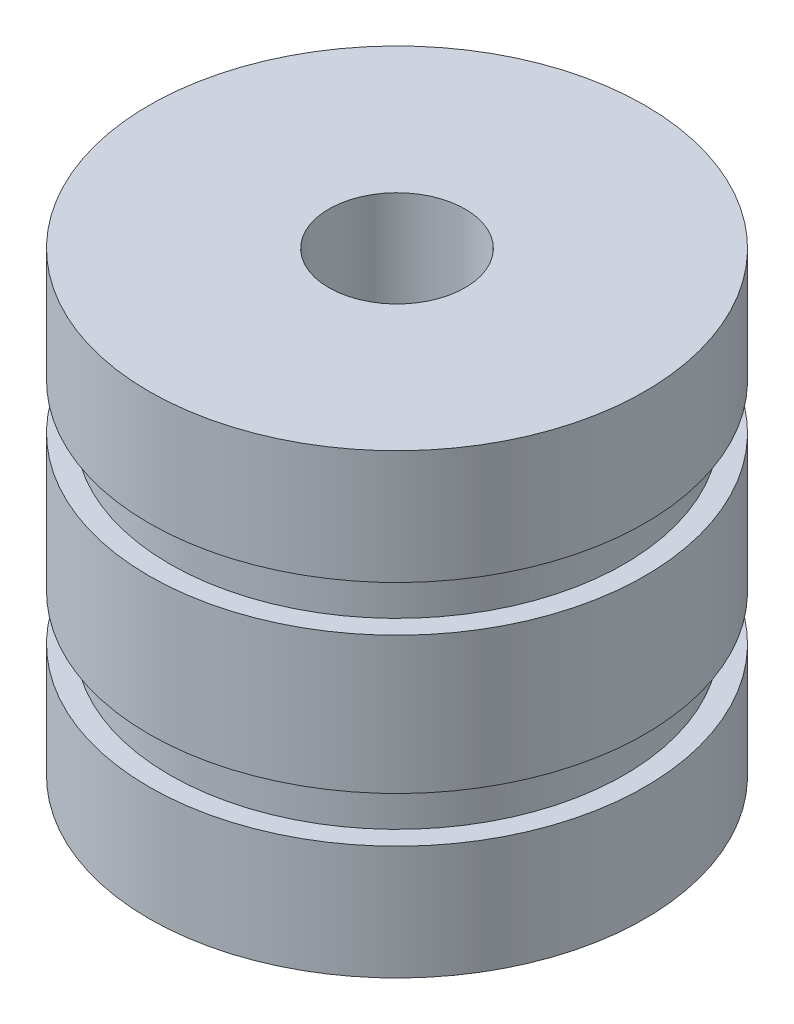
from build123d import *

# Parameters (mm, degrees)
M4X0_7_TAPPED_HOLE1_D     = 3.3
M4X0_7_TAPPED_HOLE1_DEPTH = 8
M4X0_7_TAPPED_HOLE1_TIP   = 0.991420021


with BuildPart() as part:
    # Sketch2 → Revolve1 (revolve)
    with BuildSketch(Plane.XY):
        Polygon((0, 0), (6, 0), (6, 2.762622939), (5.5, 2.762622939), (5.5, 3.867672115), (6, 3.867672115), (6, 7.185259401), (5.5, 7.185259401), (5.5, 8.290308577), (6, 8.290308577), (6, 11.052931516), (0, 11.052931516), align=None)
    revolve(axis=Axis((0, 48.827905014, 0), (0, -1, 0)))

    # M4x0.7 Tapped Hole1
    with Locations(Plane.ZX.offset(11.052931516)):
        with Locations((0, 0)):
            Hole(M4X0_7_TAPPED_HOLE1_D / 2, depth=M4X0_7_TAPPED_HOLE1_DEPTH)
            with Locations((0, 0, -(M4X0_7_TAPPED_HOLE1_DEPTH + M4X0_7_TAPPED_HOLE1_TIP / 2))):  # 118° drill point
                Cone(0, M4X0_7_TAPPED_HOLE1_D / 2, M4X0_7_TAPPED_HOLE1_TIP, mode=Mode.SUBTRACT)


solid = part.part
